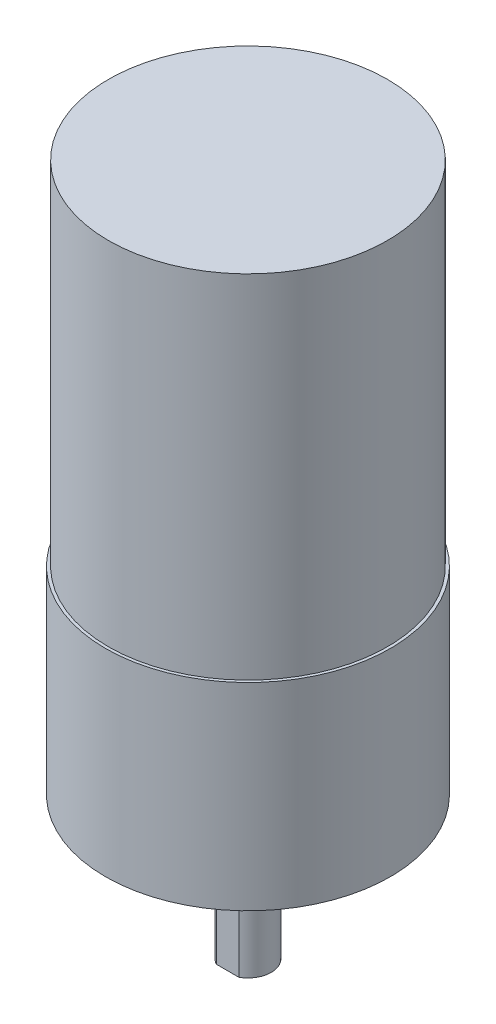
from build123d import *

# Parameters (mm, degrees)
SKETCH1_R                                       = 12.446
SKETCH1_R_2                                     = 1.27
BOSS_EXTRUDE1_DEPTH                             = 17.272
CSK_FOR_M3_FLAT_HEAD_MACHINE_SCREW1_D           = 3.4
CSK_FOR_M3_FLAT_HEAD_MACHINE_SCREW1_CSINK_D     = 6.3
CSK_FOR_M3_FLAT_HEAD_MACHINE_SCREW1_CSINK_ANGLE = 90
SKETCH5_R                                       = 12.192
BOSS_EXTRUDE2_DEPTH                             = 30.734
SKETCH6_R                                       = 3.556
BOSS_EXTRUDE3_DEPTH                             = 2.54
SKETCH7_R                                       = 2.032
BOSS_EXTRUDE4_DEPTH                             = 9.906
SKETCH8_W                                       = 2.032
SKETCH8_H                                       = 0.254
CUT_EXTRUDE2_DEPTH                              = 9.906


with BuildPart() as part:
    # Sketch1 → Boss-Extrude1 (new body)
    with BuildSketch(Plane(origin=(0, 0, 0), x_dir=(1, 0, 0), z_dir=(0, 1, 0))):
        Circle(SKETCH1_R)
        with Locations((-9.017, 0)):
            Circle(SKETCH1_R_2, mode=Mode.SUBTRACT)
        with Locations((9.017, 0)):
            Circle(SKETCH1_R_2, mode=Mode.SUBTRACT)
    extrude(amount=BOSS_EXTRUDE1_DEPTH)

    # CSK for M3 Flat Head Machine Screw1 (through all)
    with Locations(Plane(origin=(0, 17.272, 0), x_dir=(1, 0, 0), z_dir=(0, 1, 0))):
        with Locations((0, 8.119865968), (0, -7.587036194)):
            CounterSinkHole(CSK_FOR_M3_FLAT_HEAD_MACHINE_SCREW1_D / 2, CSK_FOR_M3_FLAT_HEAD_MACHINE_SCREW1_CSINK_D / 2, counter_sink_angle=CSK_FOR_M3_FLAT_HEAD_MACHINE_SCREW1_CSINK_ANGLE)

    # Sketch5 → Boss-Extrude2 (add)
    with BuildSketch(Plane(origin=(0, 17.272, 0), x_dir=(1, 0, 0), z_dir=(0, 1, 0))):
        Circle(SKETCH5_R)
    extrude(amount=BOSS_EXTRUDE2_DEPTH)

    # Sketch6 → Boss-Extrude3 (add)
    with BuildSketch(Plane(origin=(0, 0, 0), x_dir=(1, 0, 0), z_dir=(0, 1, 0))):
        Circle(SKETCH6_R)
    extrude(amount=-BOSS_EXTRUDE3_DEPTH)

    # Sketch7 → Boss-Extrude4 (add)
    with BuildSketch(Plane(origin=(0, -2.54, 0), x_dir=(-1, 0, 0), z_dir=(0, -1, 0))):
        Circle(SKETCH7_R)
    extrude(amount=BOSS_EXTRUDE4_DEPTH)

    # Sketch8 → Cut-Extrude2 (cut)
    with BuildSketch(Plane(origin=(0, -12.446, 0), x_dir=(-1, 0, 0), z_dir=(0, -1, 0))):
        with Locations((0, -1.905)):
            Rectangle(SKETCH8_W, SKETCH8_H)
        with Locations((0, 1.905)):
            Rectangle(SKETCH8_W, SKETCH8_H)
    extrude(amount=-CUT_EXTRUDE2_DEPTH, mode=Mode.SUBTRACT)


solid = part.part
